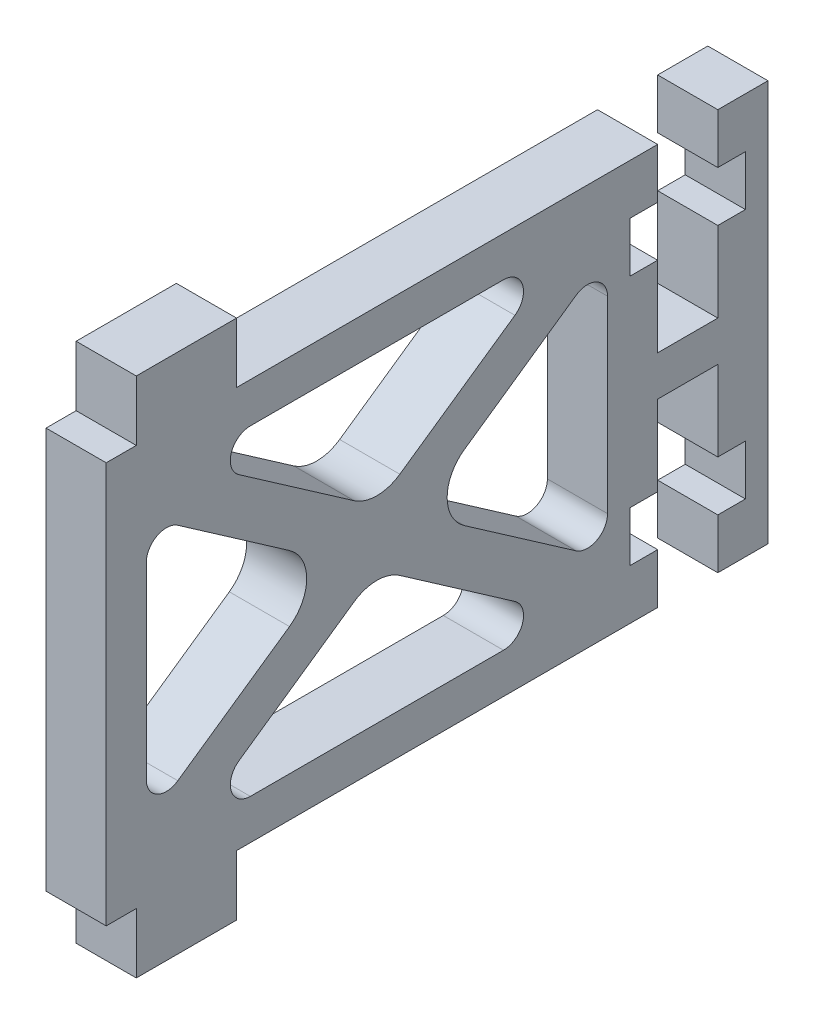
from build123d import *

# Parameters (mm, degrees)
RESSALTO_EXTRUS_O1_DEPTH = 3


with BuildPart() as part:
    # Esboço1 → Ressalto-extrusão1 (new body)
    with BuildSketch(Plane(origin=(0, 0, 0), x_dir=(0, 0, -1), z_dir=(1, 0, 0))):
        Polygon((-15.593145924, 2.125903998), (-17.093145924, 2.125903998), (-17.093145924, -17.874096002), (-15.593145924, -17.874096002), (-15.593145924, -20.874096002), (-10.593145924, -20.874096002), (-10.593145924, -17.874096002), (-9.093145924, -17.874096002), (10.406854076, -17.874096002), (10.406854076, -15.374096002), (9.031854076, -15.374096002), (9.031854076, -12.874096002), (10.406854076, -12.874096002), (10.406854076, -10.374096002), (10.406854076, -8.874096002), (13.406854076, -8.874096002), (13.406854076, -10.374096002), (13.406854076, -12.874096002), (14.781854076, -12.874096002), (14.781854076, -15.374096002), (13.406854076, -15.374096002), (13.406854076, -17.874096002), (15.906854076, -17.874096002), (15.906854076, 2.125903998), (13.406854076, 2.125903998), (13.406854076, -0.374096002), (14.781854076, -0.374096002), (14.781854076, -2.874096002), (13.406854076, -2.874096002), (13.406854076, -5.374096002), (13.406854076, -6.874096002), (10.406854076, -6.874096002), (10.406854076, -5.374096002), (10.406854076, -3.256067355), (10.406854076, -2.874096002), (9.031854076, -2.874096002), (9.031854076, -0.374096002), (10.406854076, -0.374096002), (10.406854076, 2.125903998), (-9.093145924, 2.125903998), (-10.593145924, 2.125903998), (-10.593145924, 5.125903998), (-15.593145924, 5.125903998), align=None)
        with BuildLine():
            Line((-7.953248379, -9.515906406), (-13.522081436, -13.389877228))
            ThreePointArc((-13.522081436, -13.389877228), (-14.556252559, -13.455274595), (-15.093145924, -12.568972026))
            Line((-15.093145924, -12.568972026), (-15.093145924, -3.179219979))
            ThreePointArc((-15.093145924, -3.179219979), (-14.556252559, -2.292917409), (-13.522081436, -2.358314777))
            Line((-13.522081436, -2.358314777), (-7.953248379, -6.232285599))
            ThreePointArc((-7.953248379, -6.232285599), (-7.095377355, -7.874096002), (-7.953248379, -9.515906406))
        make_face(mode=Mode.SUBTRACT)
        with BuildLine():
            Line((-4.7352749, -10.059924856), (-10.475594696, -14.053190801))
            ThreePointArc((-10.475594696, -14.053190801), (-10.858706607, -15.173340717), (-9.904530208, -15.874096002))
            Line((-9.904530208, -15.874096002), (2.71823836, -15.874096002))
            ThreePointArc((2.71823836, -15.874096002), (3.67241476, -15.173340717), (3.289302849, -14.053190801))
            Line((3.289302849, -14.053190801), (-2.451016947, -10.059924856))
            ThreePointArc((-2.451016947, -10.059924856), (-3.593145924, -9.701735259), (-4.7352749, -10.059924856))
        make_face(mode=Mode.SUBTRACT)
        with BuildLine():
            Line((0.766956531, -9.515906406), (6.335789588, -13.389877228))
            ThreePointArc((6.335789588, -13.389877228), (7.369960712, -13.455274595), (7.906854076, -12.568972026))
            Line((7.906854076, -12.568972026), (7.906854076, -10.374096002))
            Line((7.906854076, -10.374096002), (7.906854076, -3.179219979))
            ThreePointArc((7.906854076, -3.179219979), (7.369960712, -2.292917409), (6.335789588, -2.358314777))
            Line((6.335789588, -2.358314777), (0.766956531, -6.232285599))
            ThreePointArc((0.766956531, -6.232285599), (-0.090914492, -7.874096002), (0.766956531, -9.515906406))
        make_face(mode=Mode.SUBTRACT)
        with BuildLine():
            Line((3.289302849, -1.695001204), (-2.451016947, -5.688267149))
            ThreePointArc((-2.451016947, -5.688267149), (-3.593145924, -6.046456746), (-4.7352749, -5.688267149))
            Line((-4.7352749, -5.688267149), (-10.475594696, -1.695001204))
            ThreePointArc((-10.475594696, -1.695001204), (-10.858706607, -0.574851288), (-9.904530208, 0.125903998))
            Line((-9.904530208, 0.125903998), (2.71823836, 0.125903998))
            ThreePointArc((2.71823836, 0.125903998), (3.67241476, -0.574851288), (3.289302849, -1.695001204))
        make_face(mode=Mode.SUBTRACT)
    extrude(amount=RESSALTO_EXTRUS_O1_DEPTH)


solid = part.part
